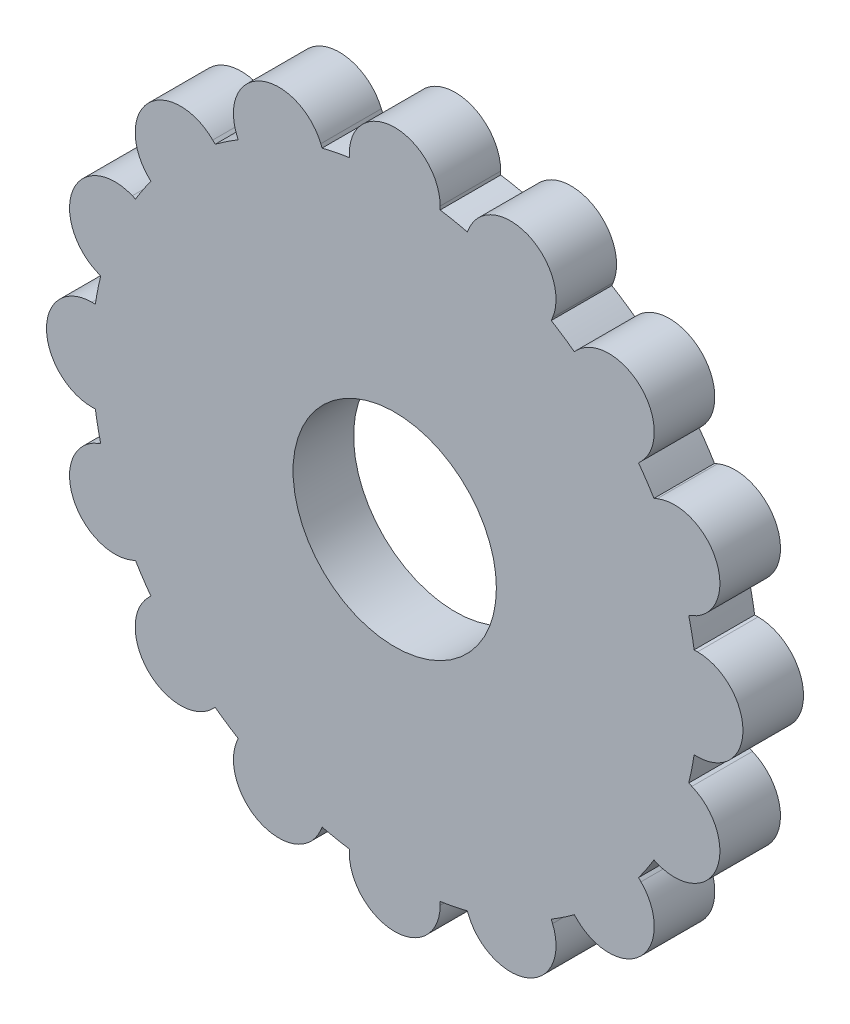
from build123d import *

# Parameters (mm, degrees)
BOSS_EXTRUDE1_DEPTH     = 10
SKETCH3_R               = 16.787014752
CUT_EXTRUDE6_DEPTH      = 11
CUT_EXTRUDE6_DEPTH_BACK = 35


with BuildPart() as part:
    # Sketch2 → Boss-Extrude1 (new body)
    with BuildSketch(Plane.XY):
        with BuildLine():
            ThreePointArc((-25.846784031, 42.801212077), (-19.134171618, 46.193976626), (-11.988591043, 48.541463563))
            Line((-11.988591043, 48.541463563), (-12.205075124, 49.064102368))
            ThreePointArc((-12.205075124, 49.064102368), (-22.004297361, 53.123073119), (-26.063268112, 43.323850883))
            Line((-26.063268112, 43.323850883), (-25.846784031, 42.801212077))
        make_face()
        with BuildLine():
            ThreePointArc((-7.5, 49.434299833), (0, 50), (7.5, 49.434299833))
            Line((7.5, 49.434299833), (7.5, 50))
            ThreePointArc((7.5, 50), (0, 57.5), (-7.5, 50))
            Line((-7.5, 50), (-7.5, 49.434299833))
        make_face()
        with BuildLine():
            Line((12.205075124, 49.064102368), (11.988591043, 48.541463563))
            ThreePointArc((11.988591043, 48.541463563), (19.134171618, 46.193976626), (25.846784031, 42.801212077))
            Line((25.846784031, 42.801212077), (26.063268112, 43.323850883))
            ThreePointArc((26.063268112, 43.323850883), (22.004297361, 53.123073119), (12.205075124, 49.064102368))
        make_face()
        with BuildLine():
            Line((30.0520382, 40.658639918), (29.652027776, 40.258629494))
            ThreePointArc((29.652027776, 40.258629494), (35.355339059, 35.355339059), (40.258629494, 29.652027776))
            Line((40.258629494, 29.652027776), (40.658639918, 30.0520382))
            ThreePointArc((40.658639918, 30.0520382), (40.658639918, 40.658639918), (30.0520382, 40.658639918))
        make_face()
        with BuildLine():
            Line((43.323850883, 26.063268112), (42.801212077, 25.846784031))
            ThreePointArc((42.801212077, 25.846784031), (46.193976626, 19.134171618), (48.541463563, 11.988591043))
            Line((48.541463563, 11.988591043), (49.064102368, 12.205075124))
            ThreePointArc((49.064102368, 12.205075124), (53.123073119, 22.004297361), (43.323850883, 26.063268112))
        make_face()
        with BuildLine():
            Line((50, 7.5), (49.434299833, 7.5))
            ThreePointArc((49.434299833, 7.5), (50, 0), (49.434299833, -7.5))
            Line((49.434299833, -7.5), (50, -7.5))
            ThreePointArc((50, -7.5), (57.5, 0), (50, 7.5))
        make_face()
        with BuildLine():
            Line((49.064102368, -12.205075124), (48.541463563, -11.988591043))
            ThreePointArc((48.541463563, -11.988591043), (46.193976626, -19.134171618), (42.801212077, -25.846784031))
            Line((42.801212077, -25.846784031), (43.323850883, -26.063268112))
            ThreePointArc((43.323850883, -26.063268112), (53.123073119, -22.004297361), (49.064102368, -12.205075124))
        make_face()
        with BuildLine():
            Line((40.658639918, -30.0520382), (40.258629494, -29.652027776))
            ThreePointArc((40.258629494, -29.652027776), (35.355339059, -35.355339059), (29.652027776, -40.258629494))
            Line((29.652027776, -40.258629494), (30.0520382, -40.658639918))
            ThreePointArc((30.0520382, -40.658639918), (40.658639918, -40.658639918), (40.658639918, -30.0520382))
        make_face()
        with BuildLine():
            Line((26.063268112, -43.323850883), (25.846784031, -42.801212077))
            ThreePointArc((25.846784031, -42.801212077), (19.134171618, -46.193976626), (11.988591043, -48.541463563))
            Line((11.988591043, -48.541463563), (12.205075124, -49.064102368))
            ThreePointArc((12.205075124, -49.064102368), (22.004297361, -53.123073119), (26.063268112, -43.323850883))
        make_face()
        with BuildLine():
            Line((7.5, -50), (7.5, -49.434299833))
            ThreePointArc((7.5, -49.434299833), (0, -50), (-7.5, -49.434299833))
            Line((-7.5, -49.434299833), (-7.5, -50))
            ThreePointArc((-7.5, -50), (0, -57.5), (7.5, -50))
        make_face()
        with BuildLine():
            ThreePointArc((-11.988591043, -48.541463563), (-19.134171618, -46.193976626), (-25.846784031, -42.801212077))
            Line((-25.846784031, -42.801212077), (-26.063268112, -43.323850883))
            ThreePointArc((-26.063268112, -43.323850883), (-22.004297361, -53.123073119), (-12.205075124, -49.064102368))
            Line((-12.205075124, -49.064102368), (-11.988591043, -48.541463563))
        make_face()
        with BuildLine():
            ThreePointArc((-29.652027776, -40.258629494), (-35.355339059, -35.355339059), (-40.258629494, -29.652027776))
            Line((-40.258629494, -29.652027776), (-40.658639918, -30.0520382))
            ThreePointArc((-40.658639918, -30.0520382), (-40.658639918, -40.658639918), (-30.0520382, -40.658639918))
            Line((-30.0520382, -40.658639918), (-29.652027776, -40.258629494))
        make_face()
        with BuildLine():
            ThreePointArc((-42.801212077, -25.846784031), (-46.193976626, -19.134171618), (-48.541463563, -11.988591043))
            Line((-48.541463563, -11.988591043), (-49.064102368, -12.205075124))
            ThreePointArc((-49.064102368, -12.205075124), (-53.123073119, -22.004297361), (-43.323850883, -26.063268112))
            Line((-43.323850883, -26.063268112), (-42.801212077, -25.846784031))
        make_face()
        with BuildLine():
            ThreePointArc((-49.434299833, -7.5), (-50, 0), (-49.434299833, 7.5))
            Line((-49.434299833, 7.5), (-50, 7.5))
            ThreePointArc((-50, 7.5), (-57.5, 0), (-50, -7.5))
            Line((-50, -7.5), (-49.434299833, -7.5))
        make_face()
        with BuildLine():
            ThreePointArc((-48.541463563, 11.988591043), (-46.193976626, 19.134171618), (-42.801212077, 25.846784031))
            Line((-42.801212077, 25.846784031), (-43.323850883, 26.063268112))
            ThreePointArc((-43.323850883, 26.063268112), (-53.123073119, 22.004297361), (-49.064102368, 12.205075124))
            Line((-49.064102368, 12.205075124), (-48.541463563, 11.988591043))
        make_face()
        with BuildLine():
            Line((-40.258629494, 29.652027776), (-40.658639918, 30.0520382))
            ThreePointArc((-40.658639918, 30.0520382), (-40.658639918, 40.658639918), (-30.0520382, 40.658639918))
            Line((-30.0520382, 40.658639918), (-29.652027776, 40.258629494))
            ThreePointArc((-29.652027776, 40.258629494), (35.355339059, -35.355339059), (-40.258629494, 29.652027776))
        make_face()
    extrude(amount=BOSS_EXTRUDE1_DEPTH)

    # Sketch3 → Cut-Extrude6 (cut, two sides)
    with BuildSketch(Plane.XY) as cut_extrude6_sk:
        Circle(SKETCH3_R)
    extrude(amount=CUT_EXTRUDE6_DEPTH, mode=Mode.SUBTRACT)
    extrude(cut_extrude6_sk.sketch, amount=-CUT_EXTRUDE6_DEPTH_BACK, mode=Mode.SUBTRACT)


solid = part.part
